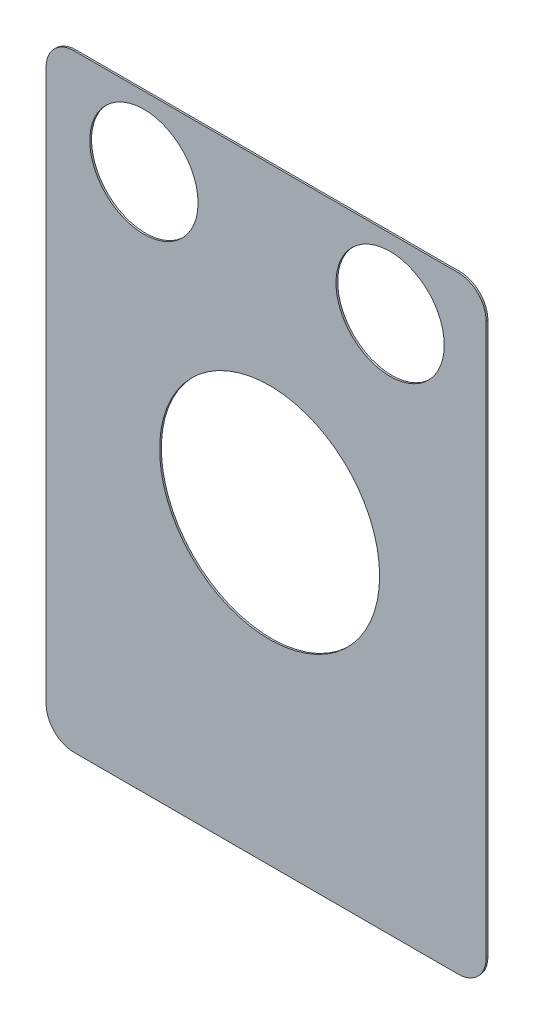
from build123d import *

# Parameters (mm, degrees)
BOSS_EXTRUDE1_DEPTH = 0.254
SKETCH2_R           = 7.874
CUT_EXTRUDE1_DEPTH  = 0.254
SKETCH3_R           = 16.002
CUT_EXTRUDE2_DEPTH  = 0.254


with BuildPart() as part:
    # Sketch1 → Boss-Extrude1 (new body)
    with BuildSketch(Plane.XY):
        with BuildLine():
            Line((-27.94, -44.196), (27.94, -44.196))
            ThreePointArc((27.94, -44.196), (30.813681959, -43.005681959), (32.004, -40.132))
            Line((32.004, -40.132), (32.004, 40.132))
            ThreePointArc((32.004, 40.132), (30.813681959, 43.005681959), (27.94, 44.196))
            Line((27.94, 44.196), (-27.94, 44.196))
            ThreePointArc((-27.94, 44.196), (-30.813681959, 43.005681959), (-32.004, 40.132))
            Line((-32.004, 40.132), (-32.004, -40.132))
            ThreePointArc((-32.004, -40.132), (-30.813681959, -43.005681959), (-27.94, -44.196))
        make_face()
    extrude(amount=-BOSS_EXTRUDE1_DEPTH)

    # Sketch2 → Cut-Extrude1 (cut)
    with BuildSketch(Plane.XY):
        with Locations((18.034, 34.036)):
            Circle(SKETCH2_R)
        with Locations((-17.78, 34.036)):
            Circle(SKETCH2_R)
    extrude(amount=-CUT_EXTRUDE1_DEPTH, mode=Mode.SUBTRACT)

    # Sketch3 → Cut-Extrude2 (cut)
    with BuildSketch(Plane.XY):
        with Locations((0.508, 0.254)):
            Circle(SKETCH3_R)
    extrude(amount=-CUT_EXTRUDE2_DEPTH, mode=Mode.SUBTRACT)


solid = part.part
